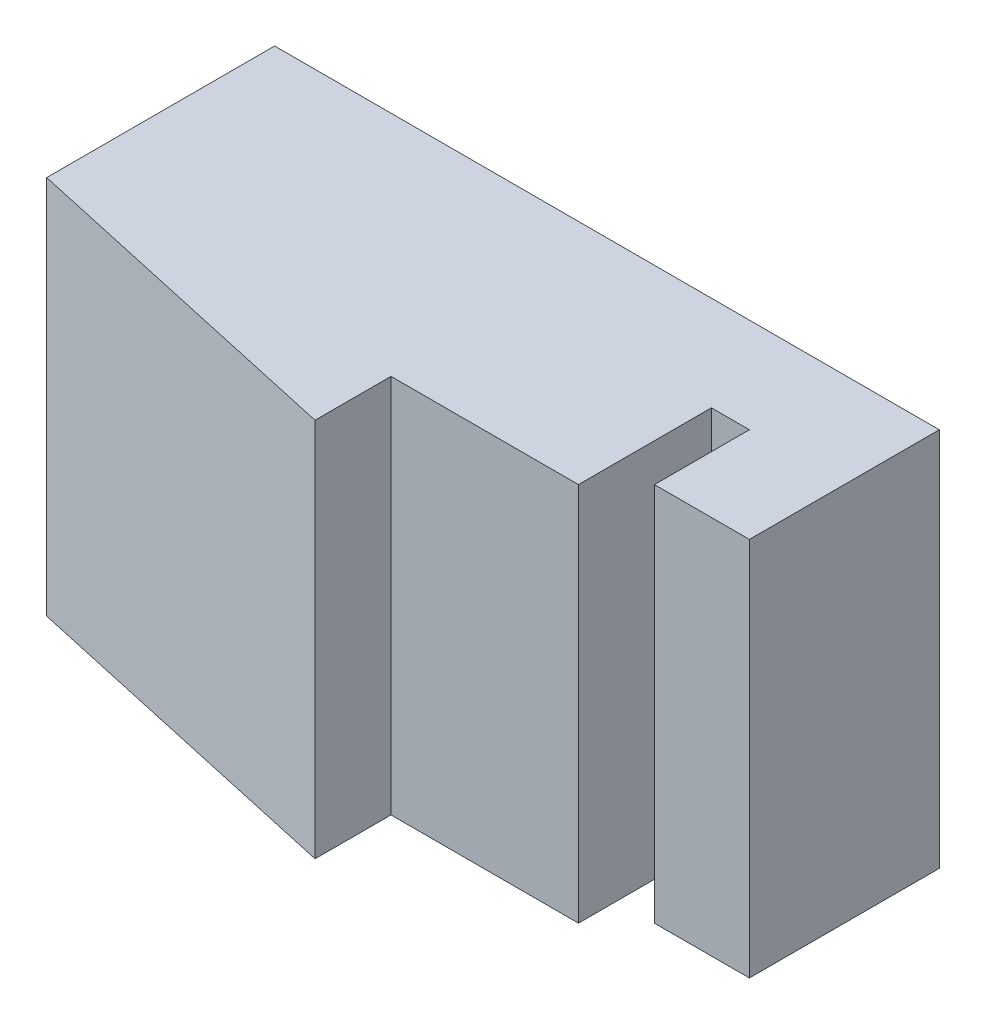
from build123d import *

# Parameters (mm, degrees)
BOSS_EXTRUDE1_DEPTH = 20


with BuildPart() as part:
    # Sketch1 → Boss-Extrude1 (new body)
    with BuildSketch(Plane(origin=(0, 0, 0), x_dir=(1, 0, 0), z_dir=(0, 1, 0))):
        Polygon((-27.628997906, 0), (7.371002094, 0), (7.371002094, -10), (2.371002094, -10), (2.371002094, -5), (0.371002094, -5), (0.371002094, -12), (-9.5, -12), (-9.5, -16), (-27.628997906, -12), align=None)
    extrude(amount=BOSS_EXTRUDE1_DEPTH)


solid = part.part
